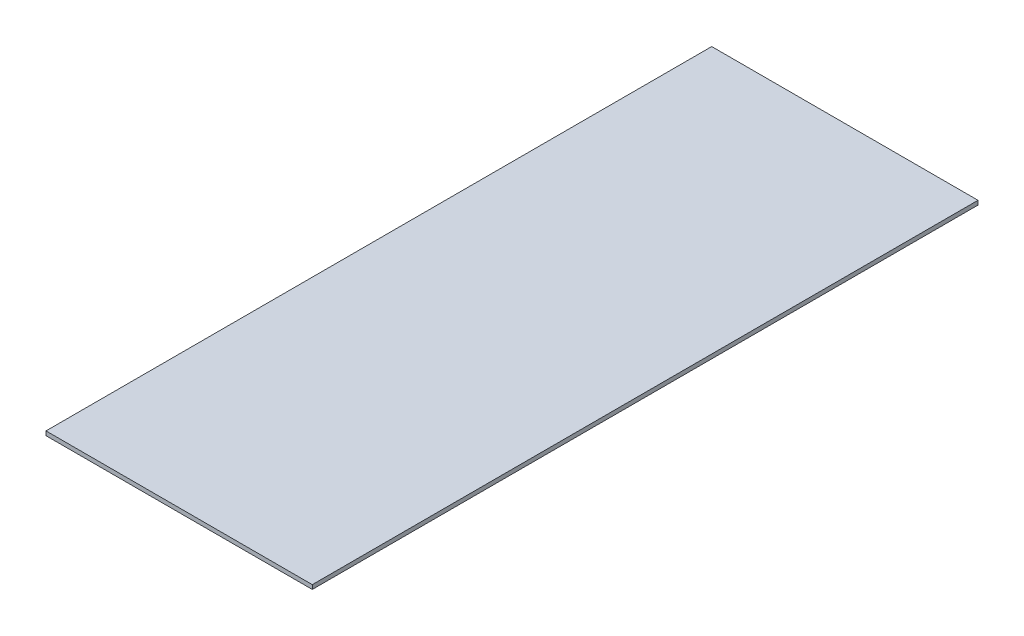
from build123d import *

# Parameters (mm, degrees)
SKETCH1_W           = 202
SKETCH1_H           = 505
BOSS_EXTRUDE1_DEPTH = 3.175


with BuildPart() as part:
    # Sketch1 → Boss-Extrude1 (new body)
    with BuildSketch(Plane(origin=(0, 0, 0), x_dir=(1, 0, 0), z_dir=(0, 1, 0))):
        with Locations((101, 252.5)):
            Rectangle(SKETCH1_W, SKETCH1_H)
    extrude(amount=BOSS_EXTRUDE1_DEPTH)


solid = part.part
